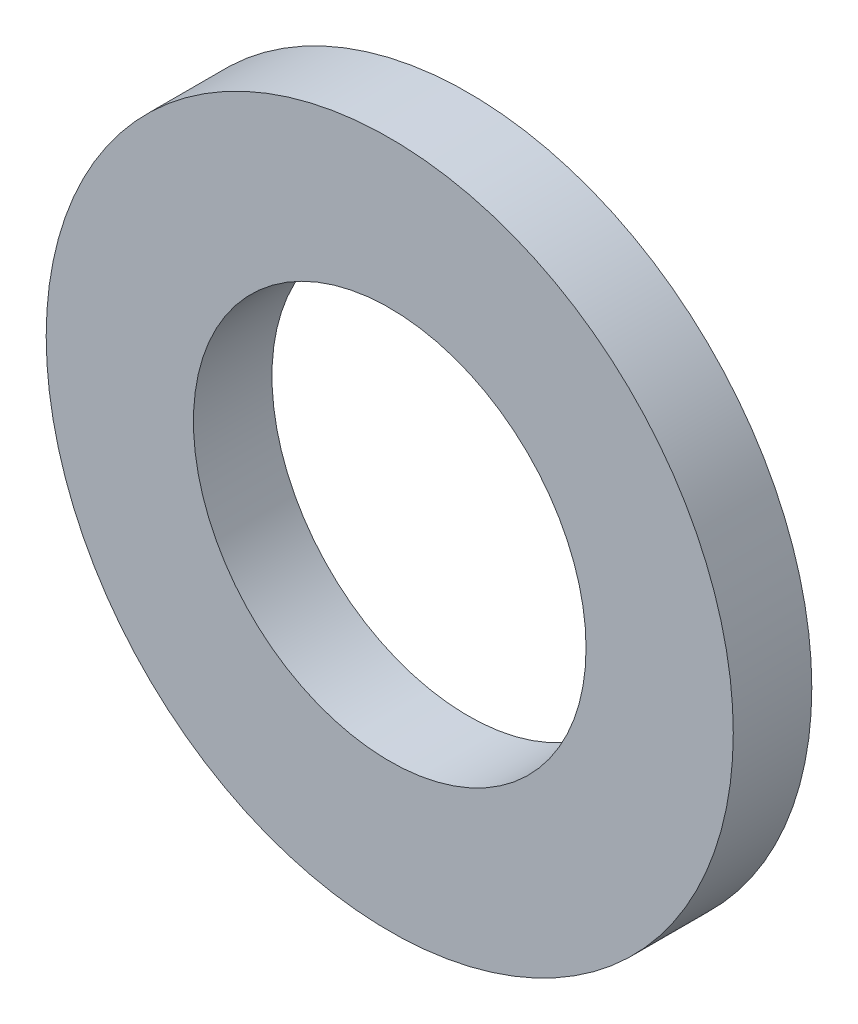
from build123d import *

# Parameters (mm, degrees)
SKETCH_1_R      = 17.5
SKETCH_1_R_2    = 10
EXTRUDE_1_DEPTH = 4


with BuildPart() as part:
    # 草图1 → 凸台-拉伸1 (new body)
    with BuildSketch(Plane.XY):
        Circle(SKETCH_1_R)
        Circle(SKETCH_1_R_2, mode=Mode.SUBTRACT)
    extrude(amount=EXTRUDE_1_DEPTH)


solid = part.part
